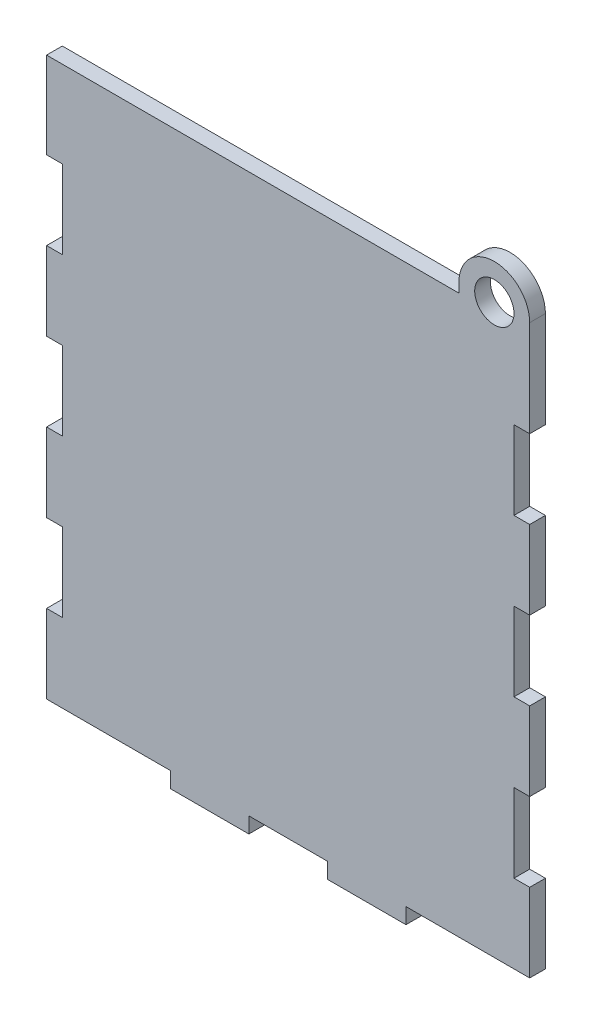
from build123d import *

# Parameters (mm, degrees)
SKETCH_1_R      = 5
EXTRUDE_1_DEPTH = 4


with BuildPart() as part:
    # Эскиз1 → Бобышка-Вытянуть1 (new body)
    with BuildSketch(Plane.XY):
        with BuildLine():
            Line((31.5, 0), (31.5, -4))
            Line((31.5, -4), (51.5, -4))
            Line((51.5, -4), (51.5, 0))
            Line((51.5, 0), (71.5, 0))
            Line((71.5, 0), (71.5, -4))
            Line((71.5, -4), (91.5, -4))
            Line((91.5, -4), (91.5, 0))
            Line((91.5, 0), (123, 0))
            Line((123, 0), (123, 20))
            Line((123, 20), (119, 20))
            Line((119, 20), (119, 40))
            Line((119, 40), (123, 40))
            Line((123, 40), (123, 60))
            Line((123, 60), (119, 60))
            Line((119, 60), (119, 80))
            Line((119, 80), (123, 80))
            Line((123, 80), (123, 100))
            Line((123, 100), (119, 100))
            Line((119, 100), (119, 120))
            Line((119, 120), (123, 120))
            Line((123, 120), (123, 144.5))
            ThreePointArc((123, 144.5), (114, 153.5), (105, 144.5))
            Line((105, 144.5), (105, 142))
            Line((105, 142), (0, 142))
            Line((0, 142), (0, 120))
            Line((0, 120), (4, 120))
            Line((4, 120), (4, 100))
            Line((4, 100), (0, 100))
            Line((0, 100), (0, 80))
            Line((0, 80), (4, 80))
            Line((4, 80), (4, 60))
            Line((4, 60), (0, 60))
            Line((0, 60), (0, 40))
            Line((0, 40), (4, 40))
            Line((4, 40), (4, 20))
            Line((4, 20), (0, 20))
            Line((0, 20), (0, 0))
            Line((0, 0), (31.5, 0))
        make_face()
        with Locations((114, 144.5)):
            Circle(SKETCH_1_R, mode=Mode.SUBTRACT)
    extrude(amount=EXTRUDE_1_DEPTH)


solid = part.part
